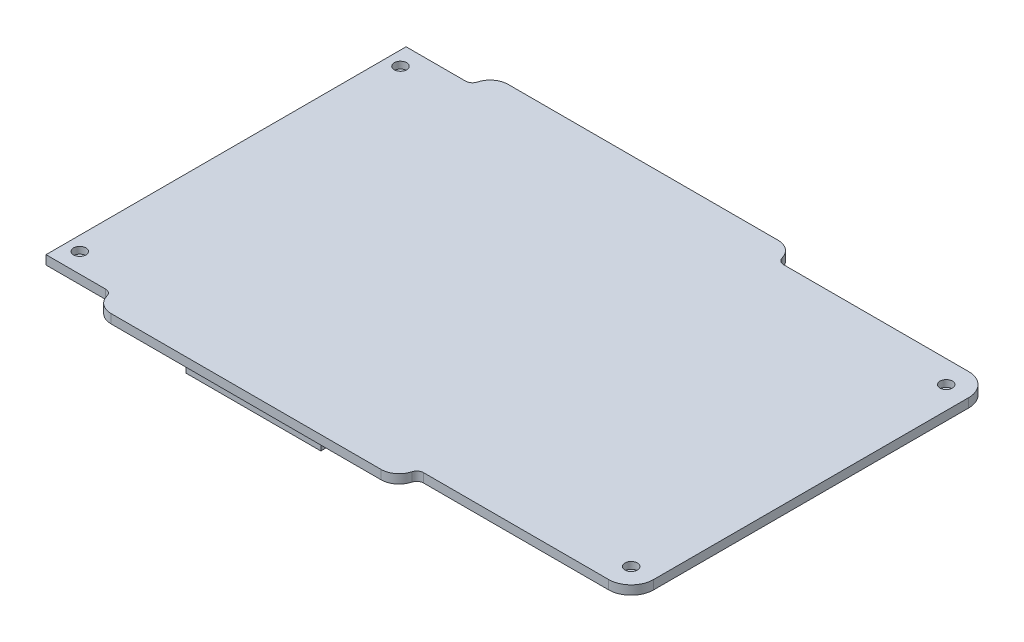
from build123d import *

# Parameters (mm, degrees)
BOSS_EXTRUDE1_DEPTH = 4
FILLET1_R           = 3
FILLET2_R           = 8
FILLET3_R           = 10
SKETCH2_R           = 2.75
CUT_EXTRUDE2_DEPTH  = 4
SKETCH3_W           = 60
SKETCH3_H           = 4
BOSS_EXTRUDE2_DEPTH = 6
CHAMFER1_SIZE       = 0.5
SKETCH2_3_R         = 2.75
BOSS_EXTRUDE3_DEPTH = 1


with BuildPart() as part:
    # Sketch1 → Boss-Extrude1 (new body)
    with BuildSketch(Plane(origin=(0, 0, 0), x_dir=(1, 0, 0), z_dir=(0, 1, 0))):
        Polygon((29.5, 168.2), (29.5, 160), (0, 160), (0, 80), (0, 0), (29.5, 0), (29.5, -8.2), (164.72, -8.2), (164.72, 0), (260, 0), (260, 160), (164.72, 160), (164.72, 168.2), align=None)
    extrude(amount=BOSS_EXTRUDE1_DEPTH)

    # Fillet1
    fillet1_edges = [part.edges().sort_by_distance(p)[0] for p in [
        (29.5, 2, -160),
        (164.72, 2, -160),
        (164.72, 2, 0),
        (29.5, 2, 0),
    ]]
    fillet(fillet1_edges, radius=FILLET1_R)

    # Fillet2
    fillet2_edges = [part.edges().sort_by_distance(p)[0] for p in [
        (29.5, 2, -168.2),
        (164.72, 2, -168.2),
        (29.5, 2, 8.2),
        (164.72, 2, 8.2),
    ]]
    fillet(fillet2_edges, radius=FILLET2_R)

    # Fillet3
    fillet3_edges = [part.edges().sort_by_distance(p)[0] for p in [
        (260, 2, -160),
        (260, 2, 0),
    ]]
    fillet(fillet3_edges, radius=FILLET3_R)

    # Sketch2 → Cut-Extrude2 (cut)
    with BuildSketch(Plane(origin=(0, 0, 0), x_dir=(1, 0, 0), z_dir=(0, 1, 0))):
        with Locations((6.25, 151.25)):
            Circle(SKETCH2_R)
        with Locations((250, 150)):
            Circle(SKETCH2_R)
        with Locations((250, 10)):
            Circle(SKETCH2_R)
        with Locations((6.25, 8.75)):
            Circle(SKETCH2_R)
    extrude(amount=CUT_EXTRUDE2_DEPTH, mode=Mode.SUBTRACT)

    # Sketch3 → Boss-Extrude2 (add)
    with BuildSketch(Plane(origin=(0, 0, 0), x_dir=(1, 0, 0), z_dir=(0, 1, 0))):
        with Locations((97.11, 163)):
            Rectangle(SKETCH3_W, SKETCH3_H)
        with Locations((97.11, -3)):
            Rectangle(SKETCH3_W, SKETCH3_H)
    extrude(amount=-BOSS_EXTRUDE2_DEPTH)

    # Chamfer1
    chamfer1_edges = [part.edges().sort_by_distance(p)[0] for p in [
        (127.11, -6, 3),
        (97.11, -6, 5),
        (67.11, -6, 3),
        (97.11, -6, 1),
        (67.11, -6, -163),
        (97.11, -6, -161),
        (127.11, -6, -163),
        (97.11, -6, -165),
    ]]
    chamfer(chamfer1_edges, length=CHAMFER1_SIZE)

    # Sketch2_3 → Boss-Extrude3 (add)
    with BuildSketch(Plane(origin=(0, 0, 0), x_dir=(1, 0, 0), z_dir=(0, 1, 0))):
        with Locations((6.25, 151.25)):
            Circle(SKETCH2_3_R)
        with Locations((250, 150)):
            Circle(SKETCH2_3_R)
        with Locations((250, 10)):
            Circle(SKETCH2_3_R)
        with Locations((6.25, 8.75)):
            Circle(SKETCH2_3_R)
    extrude(amount=BOSS_EXTRUDE3_DEPTH)


solid = part.part
